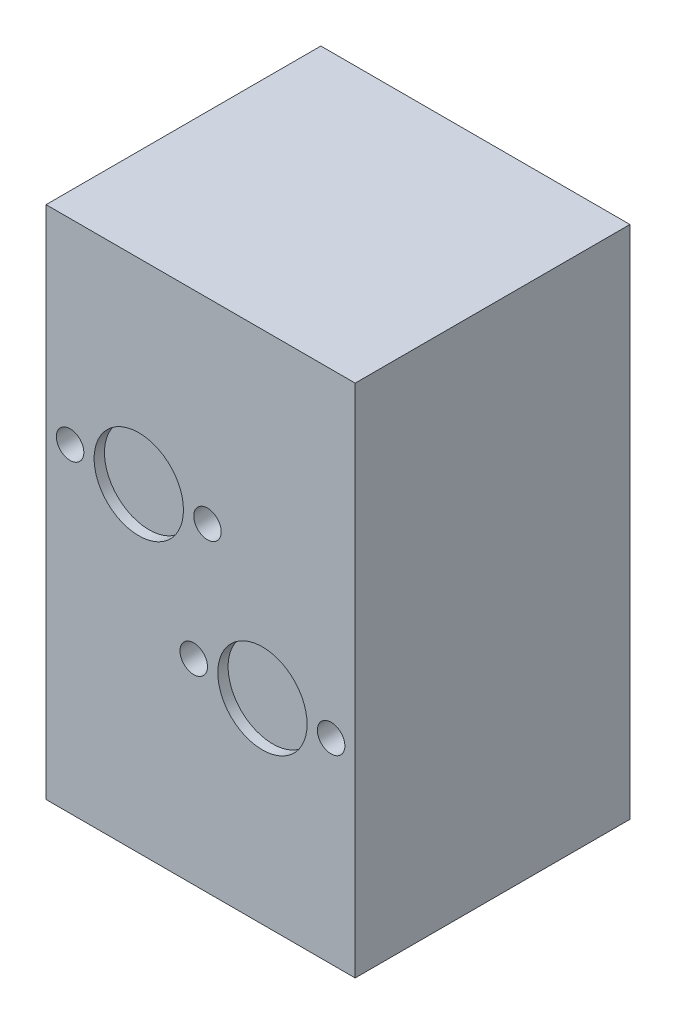
from build123d import *

# Parameters (mm, degrees)
SKETCH_1_W          = 90
SKETCH_1_H          = 150
EXTRUDE_1_DEPTH     = 80
SKETCH_2_R          = 13
CUT_EXTRUDE_1_DEPTH = 3
SKETCH_3_R          = 4
CUT_EXTRUDE_2_DEPTH = 10
SKETCH_4_R          = 4
CUT_EXTRUDE_3_DEPTH = 7


with BuildPart() as part:
    # 草图1 → 凸台-拉伸1 (new body)
    with BuildSketch(Plane.XY):
        Rectangle(SKETCH_1_W, SKETCH_1_H)
    extrude(amount=EXTRUDE_1_DEPTH)

    # 草图2 → 切除-拉伸1 (cut)
    with BuildSketch(Plane.XY.offset(80)):
        with Locations((18, -18)):
            Circle(SKETCH_2_R)
        with Locations((-18, 18)):
            Circle(SKETCH_2_R)
    extrude(amount=-CUT_EXTRUDE_1_DEPTH, mode=Mode.SUBTRACT)

    # 草图3 → 切除-拉伸2 (cut)
    with BuildSketch(Plane.XY.offset(80)):
        with Locations((2, 18)):
            Circle(SKETCH_3_R)
        with Locations((-38, 18)):
            Circle(SKETCH_3_R)
        with Locations((-2, -18)):
            Circle(SKETCH_3_R)
        with Locations((38, -18)):
            Circle(SKETCH_3_R)
    extrude(amount=-CUT_EXTRUDE_2_DEPTH, mode=Mode.SUBTRACT)

    # 草图4 → 切除-拉伸3 (cut)
    with BuildSketch(Plane(origin=(0, 0, 0), x_dir=(-1, 0, 0), z_dir=(0, 0, -1))):
        with Locations((-19.5, 60.372983346)):
            Circle(SKETCH_4_R)
        with Locations((-19.5, -34.627016654)):
            Circle(SKETCH_4_R)
        with Locations((19.5, -34.627016654)):
            Circle(SKETCH_4_R)
        with Locations((-19.5, 34.627016654)):
            Circle(SKETCH_4_R)
        with Locations((-19.5, -60.372983346)):
            Circle(SKETCH_4_R)
        with Locations((19.5, -60.372983346)):
            Circle(SKETCH_4_R)
        with Locations((19.5, 34.627016654)):
            Circle(SKETCH_4_R)
        with Locations((19.5, 60.372983346)):
            Circle(SKETCH_4_R)
    extrude(amount=-CUT_EXTRUDE_3_DEPTH, mode=Mode.SUBTRACT)


solid = part.part
